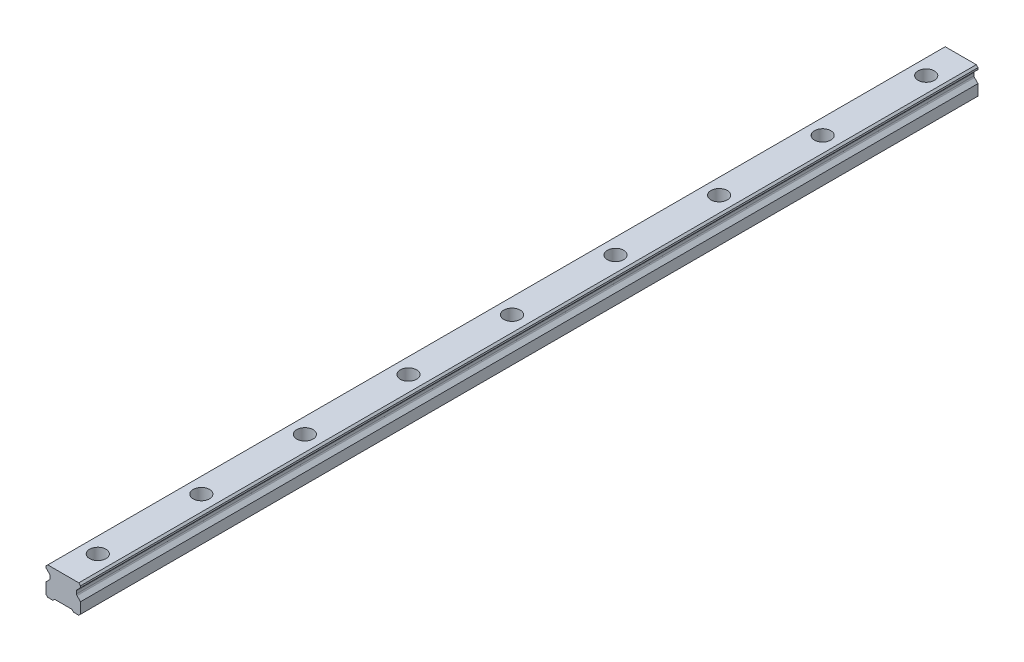
from build123d import *

# Parameters (mm, degrees)
SKETCH1_W           = 20
SKETCH1_H           = 16.3
BOSS_EXTRUDE1_DEPTH = 260
CUT_EXTRUDE1_DEPTH  = 521.351506196
CHAMFER1_SIZE       = 1
FILLET1_R           = 1
CUT_EXTRUDE2_DEPTH  = 521.351506196
SKETCH4_R           = 4.75
SKETCH4_R_2         = 3
CUT_EXTRUDE3_DEPTH  = 8.5
SKETCH4_2_R         = 3
CUT_EXTRUDE4_DEPTH  = 261.702301486
LPATTERN1_COUNT     = 9
LPATTERN1_PITCH     = 60


with BuildPart() as part:
    # Sketch1 → Boss-Extrude1 (new, symmetric)
    with BuildSketch(Plane.XY):
        with Locations((0, 8.15)):
            Rectangle(SKETCH1_W, SKETCH1_H)
    extrude(amount=BOSS_EXTRUDE1_DEPTH, both=True)

    # Sketch2 → Cut-Extrude1 (cut, through all)
    with BuildSketch(Plane.XY.offset(260)):
        Polygon((-10, 14.3), (-10, 7.3), (-7.666666667, 9.633333333), (-7.666666667, 11.966666667), align=None)
        Polygon((7.666666667, 11.966666667), (10, 14.3), (10, 7.3), (7.666666667, 9.633333333), align=None)
    extrude(amount=-CUT_EXTRUDE1_DEPTH, mode=Mode.SUBTRACT)

    # Chamfer1
    chamfer1_edges = [part.edges().sort_by_distance(p)[0] for p in [
        (-10, 16.3, 0),
        (-10, 0, 0),
        (10, 0, 0),
        (10, 16.3, 0),
    ]]
    chamfer(chamfer1_edges, length=CHAMFER1_SIZE)

    # Fillet1
    fillet1_edges = [part.edges().sort_by_distance(p)[0] for p in [
        (7.666666667, 9.633333333, 0),
        (7.666666667, 11.966666667, 0),
        (-7.666666667, 9.633333333, 0),
        (-7.666666667, 11.966666667, 0),
    ]]
    fillet(fillet1_edges, radius=FILLET1_R)

    # Sketch3 → Cut-Extrude2 (cut, through all)
    with BuildSketch(Plane.XY.offset(260)):
        Polygon((-6, 0), (-5, 1), (5, 1), (6, 0), align=None)
    extrude(amount=-CUT_EXTRUDE2_DEPTH, mode=Mode.SUBTRACT)

    # Sketch4 → Cut-Extrude3 (cut)
    with BuildSketch(Plane(origin=(0, 16.3, 0), x_dir=(1, 0, 0), z_dir=(0, 1, 0))):
        with Locations((0, -240)):
            Circle(SKETCH4_R)
        with Locations((0, -240)):
            Circle(SKETCH4_R_2, mode=Mode.SUBTRACT)
    cut_extrude3 = extrude(amount=-CUT_EXTRUDE3_DEPTH, mode=Mode.SUBTRACT)

    # Sketch4_2 → Cut-Extrude4 (cut, through all)
    with BuildSketch(Plane(origin=(0, 16.3, 0), x_dir=(1, 0, 0), z_dir=(0, 1, 0))):
        with Locations((0, -240)):
            Circle(SKETCH4_2_R)
    cut_extrude4 = extrude(amount=-CUT_EXTRUDE4_DEPTH, mode=Mode.SUBTRACT)

    # LPattern1: Cut-Extrude3, Cut-Extrude4 ×9
    with Locations(*[(0, 0, -i * LPATTERN1_PITCH) for i in range(1, LPATTERN1_COUNT)]):
        add(cut_extrude3, mode=Mode.SUBTRACT)
        add(cut_extrude4, mode=Mode.SUBTRACT)


solid = part.part
